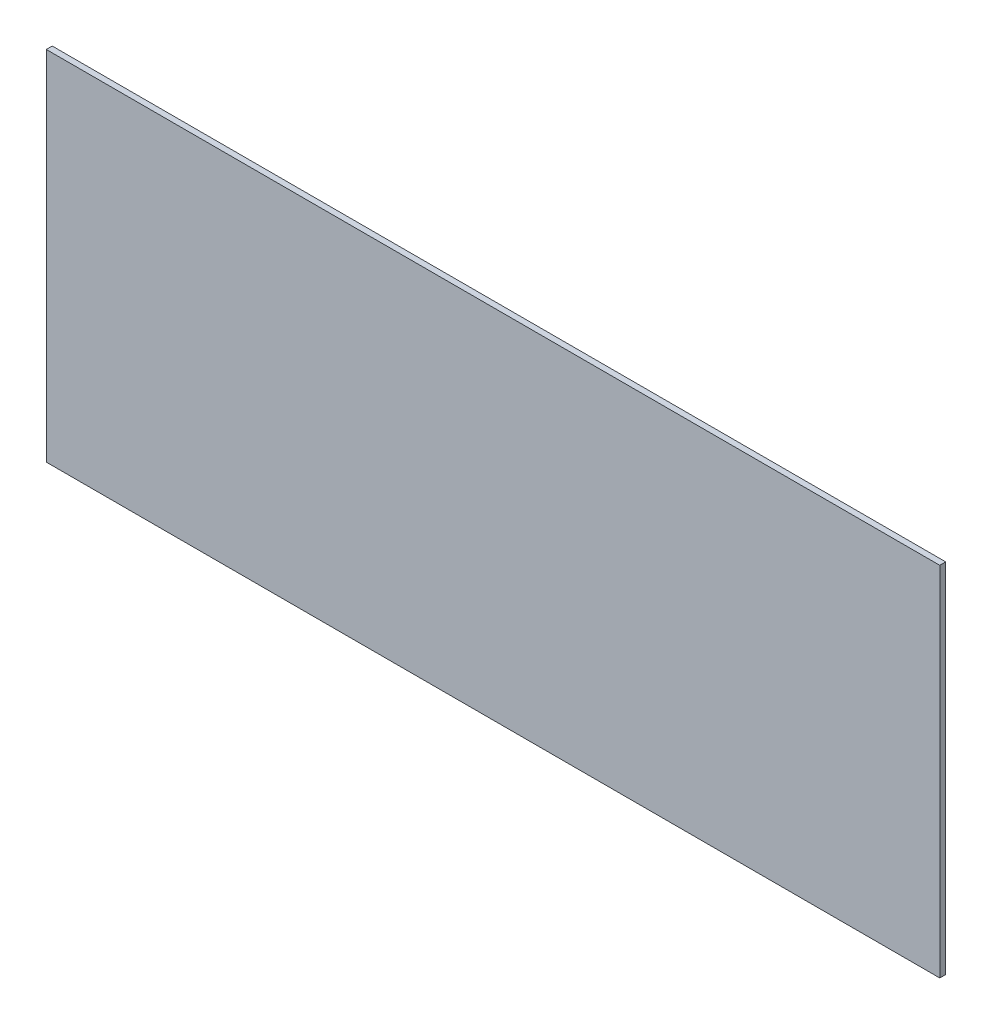
from build123d import *

# Parameters (mm, degrees)
SKETCH1_W           = 300
SKETCH1_H           = 120
BOSS_EXTRUDE1_DEPTH = 2


with BuildPart() as part:
    # Sketch1 → Boss-Extrude1 (new body)
    with BuildSketch(Plane.XY):
        with Locations((0, 23.299180328)):
            Rectangle(SKETCH1_W, SKETCH1_H)
    extrude(amount=BOSS_EXTRUDE1_DEPTH)


solid = part.part
